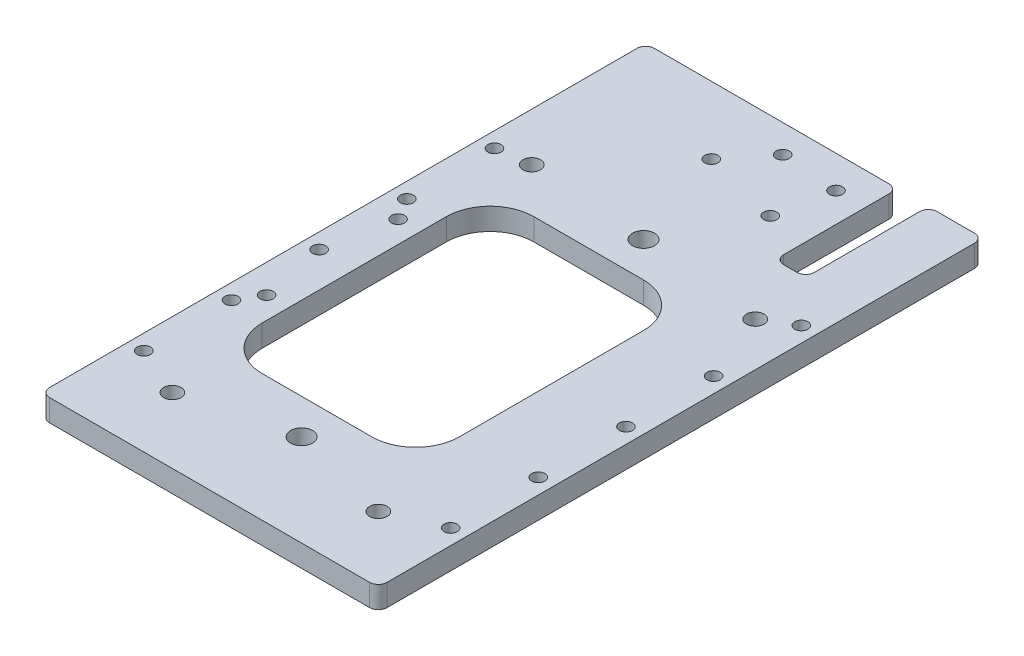
from build123d import *

# Parameters (mm, degrees)
SKETCH_1_W          = 77
SKETCH_1_H          = 138
SKETCH_1_R          = 2.5
SKETCH_1_W_2        = 45
SKETCH_1_H_2        = 62
EXTRUDE_1_DEPTH     = 5
SKETCH_7_W          = 7
SKETCH_7_H          = 28
CUT_EXTRUDE_1_DEPTH = 6
MM_CLEARANCE_0_D    = 4
FILLET_1_R          = 10
FILLET_2_R          = 2
MM_TRANSITIONAL_0_D = 3
MM_CLEARANCE_0_2_D  = 3


with BuildPart() as part:
    # 草图1 → 凸台-拉伸1 (new body)
    with BuildSketch(Plane(origin=(0, 0, 0), x_dir=(1, 0, 0), z_dir=(0, 1, 0))):
        with Locations((0, 9)):
            Rectangle(SKETCH_1_W, SKETCH_1_H)
        with Locations((0, 39)):
            Circle(SKETCH_1_R, mode=Mode.SUBTRACT)
        with Locations((0, -39)):
            Circle(SKETCH_1_R, mode=Mode.SUBTRACT)
        with Locations((-4.5, 0)):
            Rectangle(SKETCH_1_W_2, SKETCH_1_H_2, mode=Mode.SUBTRACT)
    extrude(amount=EXTRUDE_1_DEPTH)

    # 草图7 → 切除-拉伸1 (cut, through all)
    with BuildSketch(Plane(origin=(0, 5, 0), x_dir=(1, 0, 0), z_dir=(0, 1, 0))):
        with Locations((22.5, 64)):
            Rectangle(SKETCH_7_W, SKETCH_7_H)
    extrude(amount=-CUT_EXTRUDE_1_DEPTH, mode=Mode.SUBTRACT)

    # mm Clearance _0 (through all)
    with Locations(Plane(origin=(0, 0, 0), x_dir=(-1, 0, 0), z_dir=(0, -1, 0))):
        with Locations((-28.5, 36), (27.5, 41), (23.5, -45), (-23.5, -45)):
            Hole(MM_CLEARANCE_0_D / 2)

    # 圆角1
    fillet_1_edges = [part.edges().sort_by_distance(p)[0] for p in [
        (-27, 2.5, -31),
        (-27, 2.5, 31),
        (18, 2.5, 31),
        (18, 2.5, -31),
    ]]
    fillet(fillet_1_edges, radius=FILLET_1_R)

    # 圆角2
    fillet_2_edges = [part.edges().sort_by_distance(p)[0] for p in [
        (19, 2.5, -50),
        (19, 2.5, -78),
        (26, 2.5, -78),
        (26, 2.5, -50),
        (38.5, 2.5, 60),
        (-38.5, 2.5, 60),
        (-38.5, 2.5, -78),
        (38.5, 2.5, -78),
    ]]
    fillet(fillet_2_edges, radius=FILLET_2_R)

    # 大小mm Transitional 暗销孔0 (through all)
    with Locations(Plane(origin=(0, 5, 0), x_dir=(1, 0, 0), z_dir=(0, 1, 0))):
        with Locations((-31.999999999, 15), (-31.999999999, -15), (-8.142857142, 62.612808878), (-0.857142857, 71.612808878), (12.309431, 70.612808878), (9.80943136, 58.112808878)):
            Hole(MM_TRANSITIONAL_0_D / 2)

    # mm Clearance _0 2 (through all)
    with Locations(Plane(origin=(0, 5, 0), x_dir=(1, 0, 0), z_dir=(0, 1, 0))):
        with Locations((-35, 0), (-35, 20), (-35, 40), (-35, -40), (-35, -20), (35, 40), (35, 20), (35, 0), (35, -20), (35, -40)):
            Hole(MM_CLEARANCE_0_2_D / 2)


solid = part.part
